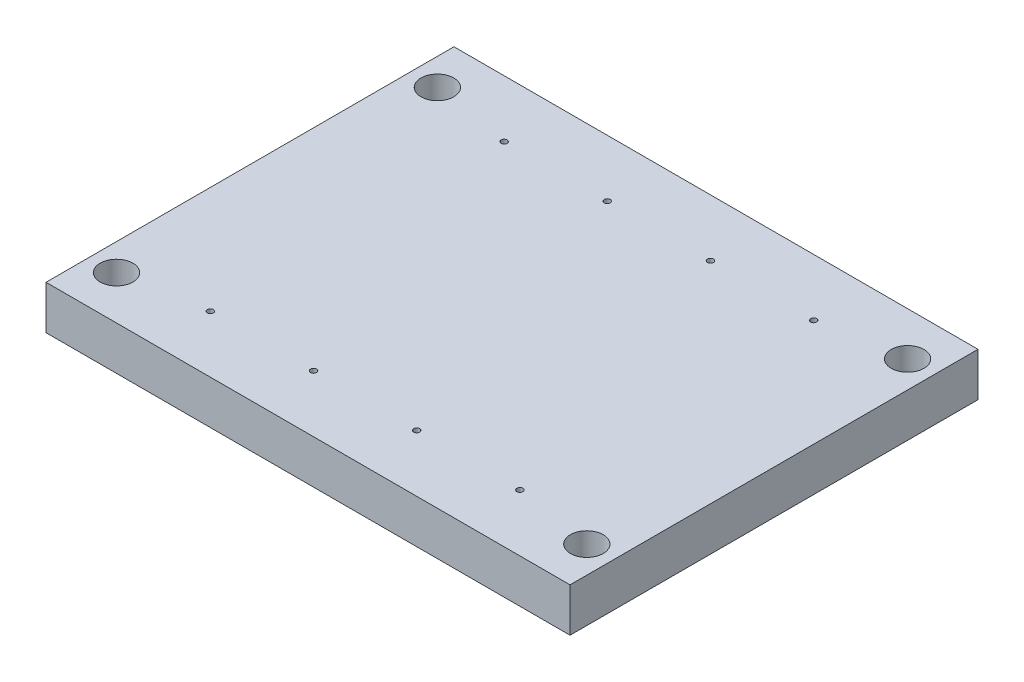
from build123d import *

# Parameters (mm, degrees)
SKETCH1_W           = 317.959323002
SKETCH1_H           = 237.284389444
BOSS_EXTRUDE1_DEPTH = 25.4
CUT_EXTRUDE1_START  = 25.4
SKETCH1_3_R         = 1.75
CUT_EXTRUDE1_DEPTH  = 6.35
SKETCH5_R           = 9.525
CUT_EXTRUDE2_DEPTH  = 26.4
CUT_EXTRUDE3_REACH  = 239.284
SKETCH6_W           = 11.775930683
SKETCH6_H           = 25.4
SKETCH6_W_2         = 11.132113684


with BuildPart() as part:
    # Sketch1 → Boss-Extrude1 (new body)
    with BuildSketch(Plane(origin=(0, 0, 0), x_dir=(1, 0, 0), z_dir=(0, 1, 0))):
        with Locations((114.5, 0)):
            Rectangle(SKETCH1_W, SKETCH1_H)
    extrude(amount=BOSS_EXTRUDE1_DEPTH)

    # Sketch1_3 → Cut-Extrude1 (cut)
    with BuildSketch(Plane(origin=(0, 0, 0), x_dir=(1, 0, 0), z_dir=(0, 1, 0)).offset(CUT_EXTRUDE1_START)):
        with Locations((24.5, 85.442194722)):
            Circle(SKETCH1_3_R)
        with Locations((84.5, 85.442194722)):
            Circle(SKETCH1_3_R)
        with Locations((144.5, 85.442194722)):
            Circle(SKETCH1_3_R)
        with Locations((204.5, 85.442194722)):
            Circle(SKETCH1_3_R)
        with Locations((24.5, -85.442194722)):
            Circle(SKETCH1_3_R)
        with Locations((84.5, -85.442194722)):
            Circle(SKETCH1_3_R)
        with Locations((144.5, -85.442194722)):
            Circle(SKETCH1_3_R)
        with Locations((204.5, -85.442194722)):
            Circle(SKETCH1_3_R)
    extrude(amount=-CUT_EXTRUDE1_DEPTH, mode=Mode.SUBTRACT)

    # Sketch5 → Cut-Extrude2 (cut, through all)
    with BuildSketch(Plane(origin=(0, 25.4, 0), x_dir=(1, 0, 0), z_dir=(0, 1, 0))):
        with Locations((-22.254661501, -93.242194722)):
            Circle(SKETCH5_R)
        with Locations((251.254661501, -93.242194722)):
            Circle(SKETCH5_R)
        with Locations((251.254661501, 93.337805278)):
            Circle(SKETCH5_R)
        with Locations((-22.254661501, 93.337805278)):
            Circle(SKETCH5_R)
    extrude(amount=-CUT_EXTRUDE2_DEPTH, mode=Mode.SUBTRACT)

    # Sketch6 → Cut-Extrude3 (cut, up to next)
    with BuildSketch(Plane.XY.offset(118.642194722), mode=Mode.PRIVATE) as cut_extrude3_sk1:
        with Locations((-43.787965342, 12.7)):
            Rectangle(SKETCH6_W, SKETCH6_H)
    cut_extrude3_tool1 = extrude(cut_extrude3_sk1.sketch, amount=-CUT_EXTRUDE3_REACH, mode=Mode.PRIVATE) & part.part
    add(cut_extrude3_tool1.solids().sort_by_distance((-43.787965, 12.7, 118.642195))[0], mode=Mode.SUBTRACT)
    # Sketch6 → Cut-Extrude3 (cut, up to next)
    with BuildSketch(Plane.XY.offset(118.642194722), mode=Mode.PRIVATE) as cut_extrude3_sk2:
        with Locations((272.466056842, 12.7)):
            Rectangle(SKETCH6_W_2, SKETCH6_H)
    cut_extrude3_tool2 = extrude(cut_extrude3_sk2.sketch, amount=-CUT_EXTRUDE3_REACH, mode=Mode.PRIVATE) & part.part
    add(cut_extrude3_tool2.solids().sort_by_distance((272.466057, 12.7, 118.642195))[0], mode=Mode.SUBTRACT)


solid = part.part
